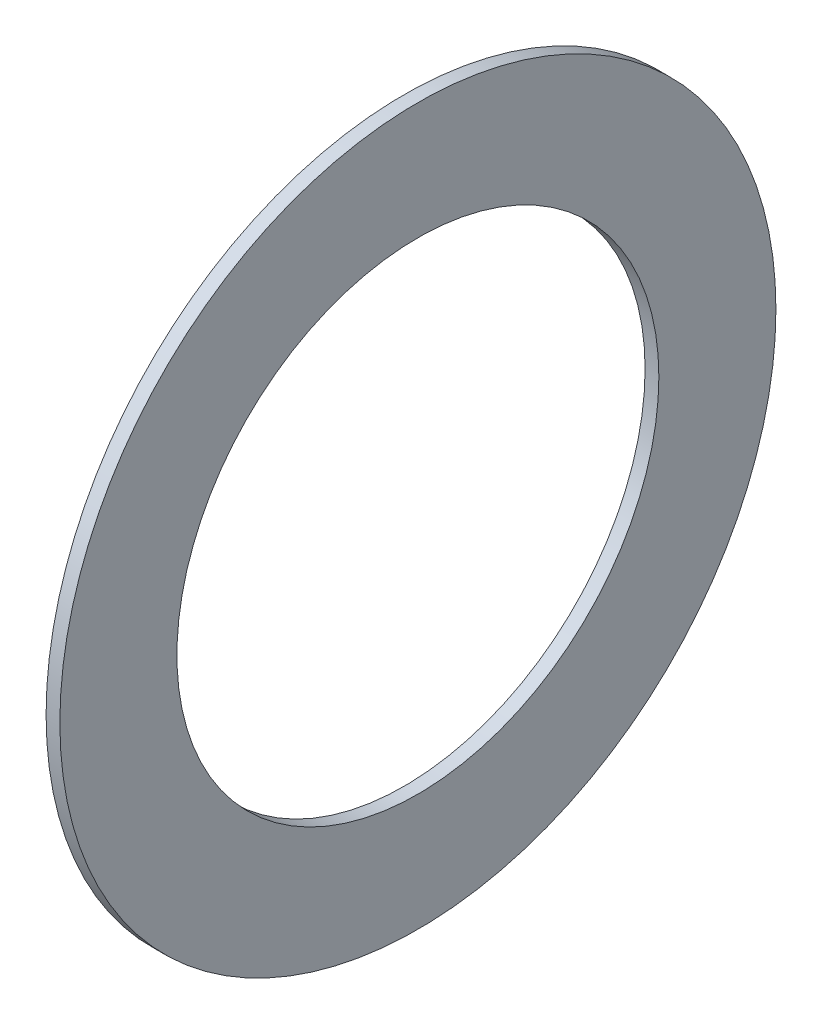
from build123d import *

# Parameters (mm, degrees)
SKETCH1_R      = 26
SKETCH1_R_2    = 17.5
EXTRUDE1_DEPTH = 1


with BuildPart() as part:
    # Sketch1 → Extrude1 (new body)
    with BuildSketch(Plane(origin=(0, 0, 0), x_dir=(0, 0, -1), z_dir=(1, 0, 0))):
        Circle(SKETCH1_R)
        Circle(SKETCH1_R_2, mode=Mode.SUBTRACT)
    extrude(amount=EXTRUDE1_DEPTH)


solid = part.part
